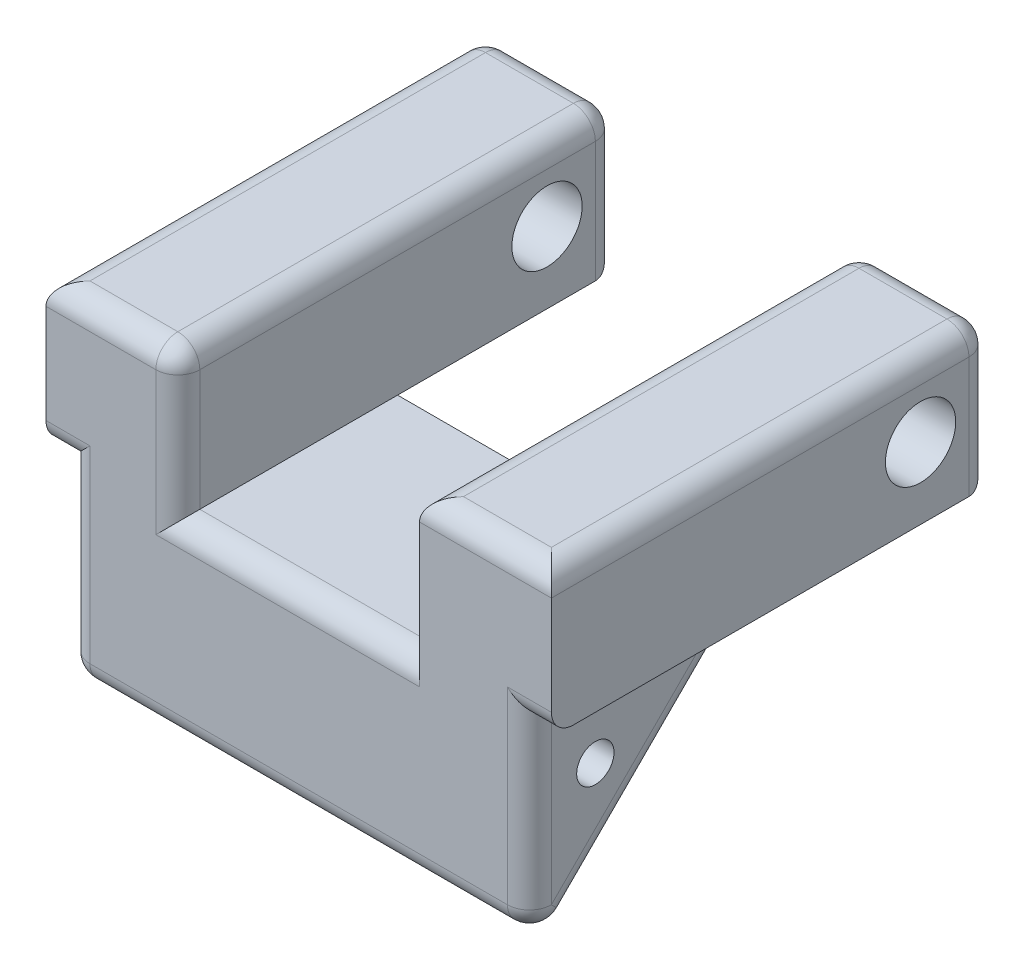
from build123d import *

# Parameters (mm, degrees)
BODY_DEPTH          = 21
SKETCH2_R           = 0.85
BOLT_HOLE_DEPTH     = 22
SKETCH3_W           = 6
SKETCH3_H           = 6.5
BOSS_EXTRUDE1_DEPTH = 20
SKETCH4_R           = 1.6
CUT_EXTRUDE1_DEPTH  = 24
EDGE_FILLETS_R      = 1


with BuildPart() as part:
    # Sketch1 → body (new body)
    with BuildSketch(Plane(origin=(0, 0, 0), x_dir=(0, 0, -1), z_dir=(1, 0, 0))):
        Polygon((0, 0), (10, 0), (0, -10), align=None)
    extrude(amount=BODY_DEPTH)

    # Sketch2 → bolt_hole (cut, through all)
    with BuildSketch(Plane.ZY):
        with Locations((-3, -3)):
            Circle(SKETCH2_R)
    extrude(amount=-BOLT_HOLE_DEPTH, mode=Mode.SUBTRACT)

    # Sketch3 → Boss-Extrude1 (add)
    with BuildSketch(Plane.XY):
        with Locations((2, 3.25)):
            Rectangle(SKETCH3_W, SKETCH3_H)
        with Locations((19, 3.25)):
            Rectangle(SKETCH3_W, SKETCH3_H)
    extrude(amount=-BOSS_EXTRUDE1_DEPTH)

    # Sketch4 → Cut-Extrude1 (cut, through all)
    with BuildSketch(Plane(origin=(22, 0, 0), x_dir=(0, 0, -1), z_dir=(1, 0, 0))):
        with Locations((16.8, 3.25)):
            Circle(SKETCH4_R)
    extrude(amount=-CUT_EXTRUDE1_DEPTH, mode=Mode.SUBTRACT)

    # edge_fillets
    edge_fillets_edges = [part.edges().sort_by_distance(p)[0] for p in [
        (21, -5, 0),
        (21, -5, -5),
        (2, 0, -20),
        (-1, 3.25, -20),
        (2, 6.5, -20),
        (-1, 6.5, -10),
        (5, 3.25, -20),
        (5, 6.5, -10),
        (-0.5, 0, 0),
        (5, 3.25, 0),
        (2, 6.5, 0),
        (10.5, 0, 0),
        (22, 3.25, -20),
        (22, 6.5, -10),
        (19, 0, -20),
        (16, 3.25, -20),
        (19, 6.5, -20),
        (16, 6.5, -10),
        (19, 6.5, 0),
        (21.5, 0, 0),
        (0, -5, -5),
        (0, -5, 0),
        (10.5, -10, 0),
    ]]
    fillet(edge_fillets_edges, radius=EDGE_FILLETS_R)


solid = part.part
